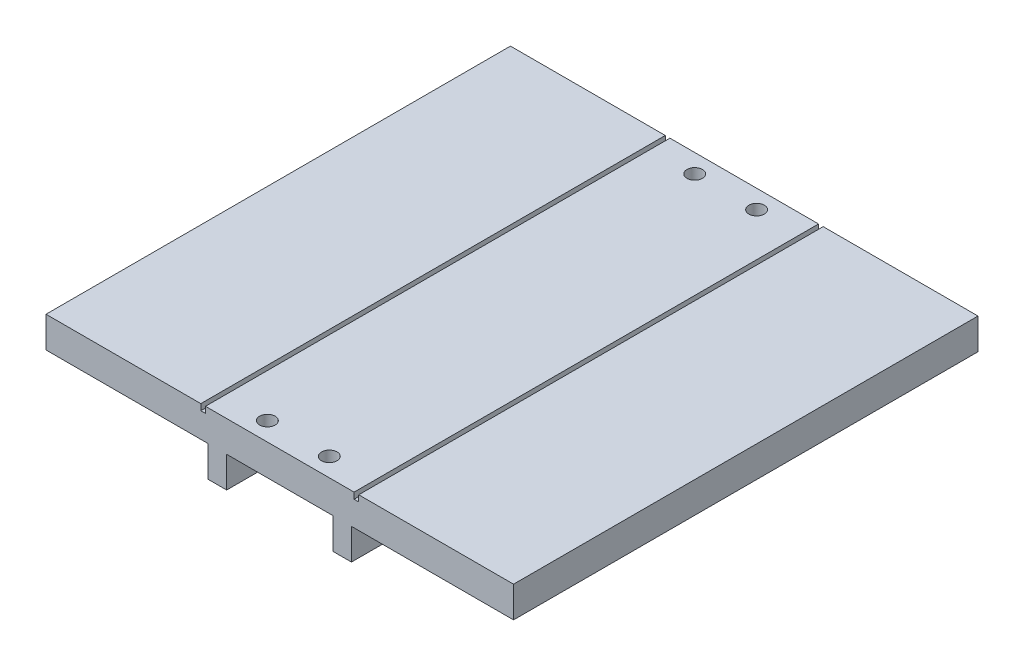
from build123d import *

# Parameters (mm, degrees)
BOSS_EXTRUDE1_DEPTH = 150
SKETCH4_R           = 1.65
CUT_EXTRUDE1_DEPTH  = 10
SKETCH6_W           = 1.5
SKETCH6_H           = 150
CUT_EXTRUDE2_DEPTH  = 2
SKETCH7_R           = 2.5
CUT_EXTRUDE3_DEPTH  = 7


with BuildPart() as part:
    # Sketch1 → Boss-Extrude1 (new body)
    with BuildSketch(Plane.XY):
        Polygon((-75.5, 5), (75.5, 5), (75.5, -5), (23.151457837, -5), (23.151457837, -15), (17.151457837, -15), (17.151457837, -5), (-17.151457837, -5), (-17.151457837, -15), (-23.151457837, -15), (-23.151457837, -5), (-75.5, -5), align=None)
    extrude(amount=BOSS_EXTRUDE1_DEPTH)

    # Sketch4 → Cut-Extrude1 (cut)
    with BuildSketch(Plane.XZ.offset(5)):
        with Locations((-10, 6)):
            Circle(SKETCH4_R)
        with Locations((10, 6)):
            Circle(SKETCH4_R)
        with Locations((-10, 144)):
            Circle(SKETCH4_R)
        with Locations((10, 144)):
            Circle(SKETCH4_R)
    extrude(amount=-CUT_EXTRUDE1_DEPTH, mode=Mode.SUBTRACT)

    # Sketch6 → Cut-Extrude2 (cut)
    with BuildSketch(Plane(origin=(0, 5, 0), x_dir=(1, 0, 0), z_dir=(0, 1, 0))):
        with Locations((-24.75, -75)):
            Rectangle(SKETCH6_W, SKETCH6_H)
        with Locations((24.75, -75)):
            Rectangle(SKETCH6_W, SKETCH6_H)
    extrude(amount=-CUT_EXTRUDE2_DEPTH, mode=Mode.SUBTRACT)

    # Sketch7 → Cut-Extrude3 (cut)
    with BuildSketch(Plane(origin=(0, 5, 0), x_dir=(1, 0, 0), z_dir=(0, 1, 0))):
        with Locations((-10, -144)):
            Circle(SKETCH7_R)
        with Locations((10, -144)):
            Circle(SKETCH7_R)
        with Locations((10, -6)):
            Circle(SKETCH7_R)
        with Locations((-10, -6)):
            Circle(SKETCH7_R)
    extrude(amount=-CUT_EXTRUDE3_DEPTH, mode=Mode.SUBTRACT)


solid = part.part
